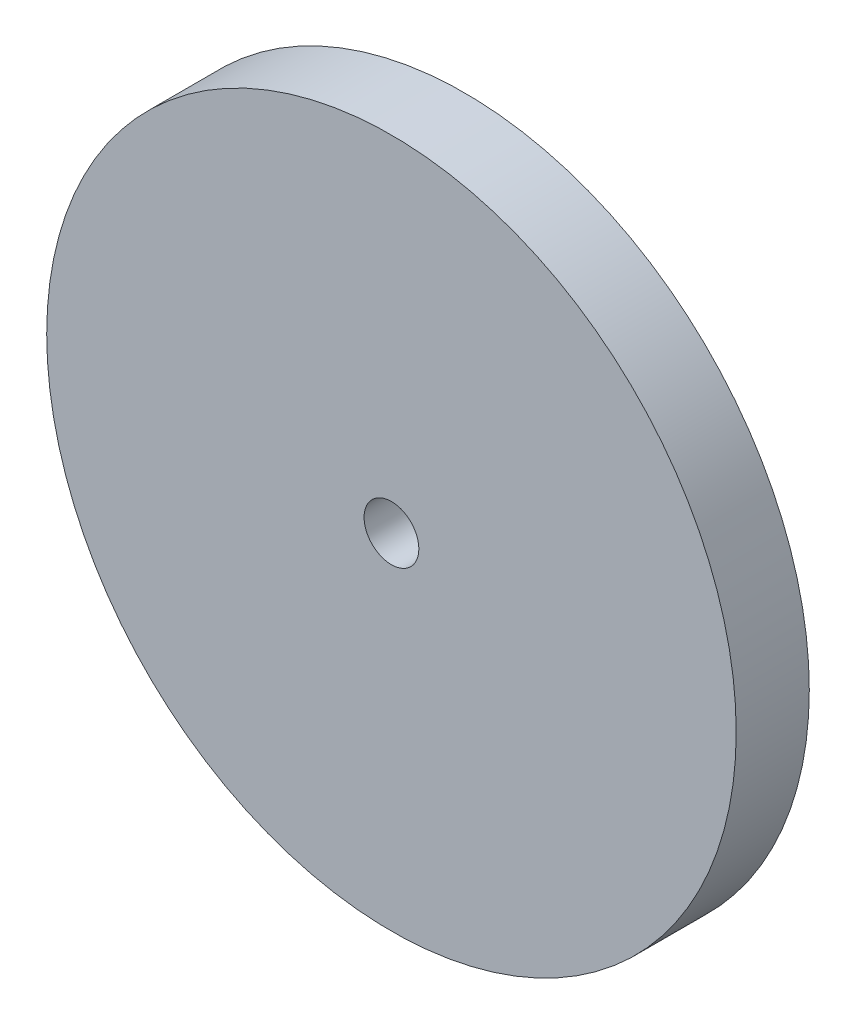
from build123d import *

# Parameters (mm, degrees)
SKETCH1_R                   = 28.3
BOSS_EXTRUDE1_DEPTH         = 6
F_16_0_177_DIAMETER_HOLE1_D = 4.4958


with BuildPart() as part:
    # Sketch1 → Boss-Extrude1 (new body)
    with BuildSketch(Plane.XY):
        Circle(SKETCH1_R)
    extrude(amount=BOSS_EXTRUDE1_DEPTH)

    # #16 (0.177) Diameter Hole1 (through all)
    with Locations(Plane.XY.offset(6)):
        with Locations((0, 0)):
            Hole(F_16_0_177_DIAMETER_HOLE1_D / 2)


solid = part.part
